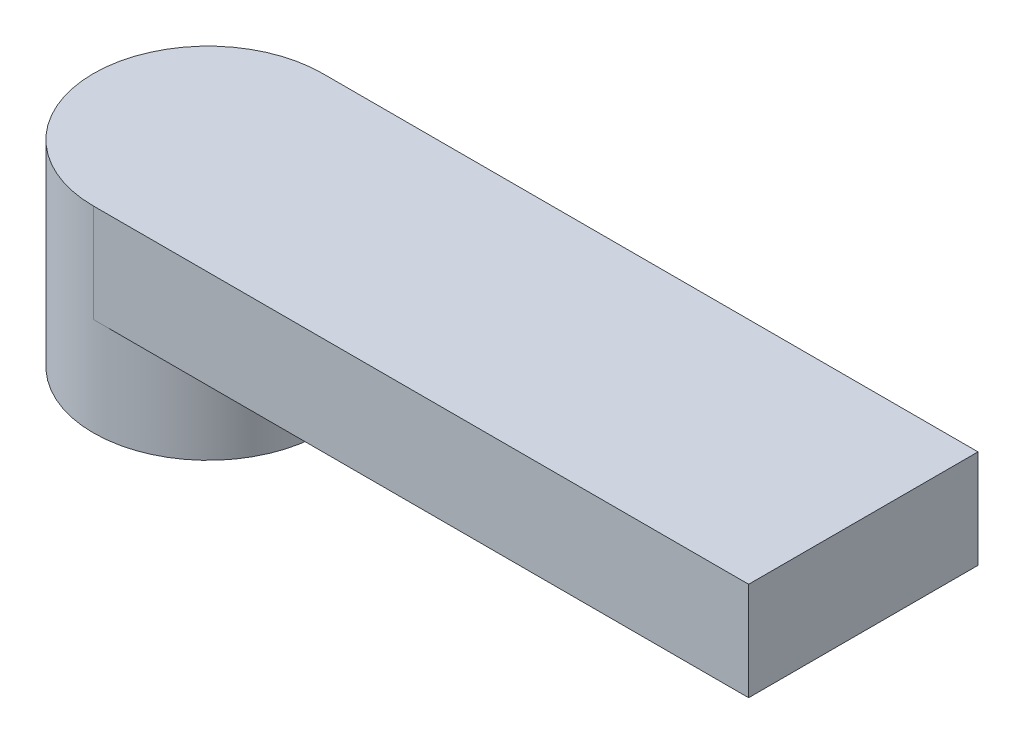
from build123d import *

# Parameters (mm, degrees)
SKETCH2_R           = 3.5
BOSS_EXTRUDE1_DEPTH = 6
SKETCH3_R           = 2.475
CUT_EXTRUDE1_DEPTH  = 2.5
BOSS_EXTRUDE2_DEPTH = 3


with BuildPart() as part:
    # Sketch2 → Boss-Extrude1 (new body)
    with BuildSketch(Plane(origin=(0, 0, 0), x_dir=(1, 0, 0), z_dir=(0, 1, 0))):
        Circle(SKETCH2_R)
    extrude(amount=BOSS_EXTRUDE1_DEPTH)

    # Sketch3 → Cut-Extrude1 (cut)
    with BuildSketch(Plane.XZ):
        Circle(SKETCH3_R)
    extrude(amount=-CUT_EXTRUDE1_DEPTH, mode=Mode.SUBTRACT)

    # Sketch4 → Boss-Extrude2 (add)
    with BuildSketch(Plane(origin=(0, 6, 0), x_dir=(1, 0, 0), z_dir=(0, 1, 0))):
        with BuildLine():
            Line((0, 3.5), (20, 3.5))
            Line((20, 3.5), (20, -3.5))
            Line((20, -3.5), (0, -3.5))
            ThreePointArc((0, -3.5), (3.5, 0), (0, 3.5))
        make_face()
    extrude(amount=-BOSS_EXTRUDE2_DEPTH)


solid = part.part
